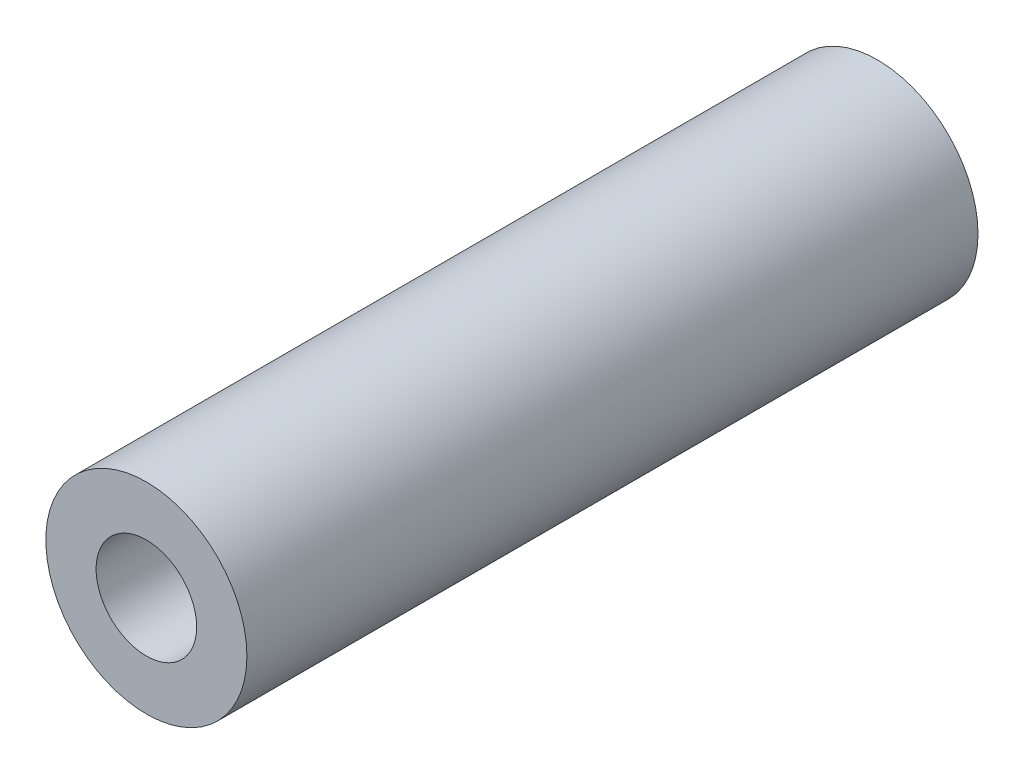
from build123d import *

# Parameters (mm, degrees)
SKETCH1_R           = 11
SKETCH1_R_2         = 5.5
BOSS_EXTRUDE1_DEPTH = 40


with BuildPart() as part:
    # Sketch1 → Boss-Extrude1 (new body, symmetric)
    with BuildSketch(Plane.XY):
        Circle(SKETCH1_R)
        Circle(SKETCH1_R_2, mode=Mode.SUBTRACT)
    extrude(amount=BOSS_EXTRUDE1_DEPTH, both=True)


solid = part.part
